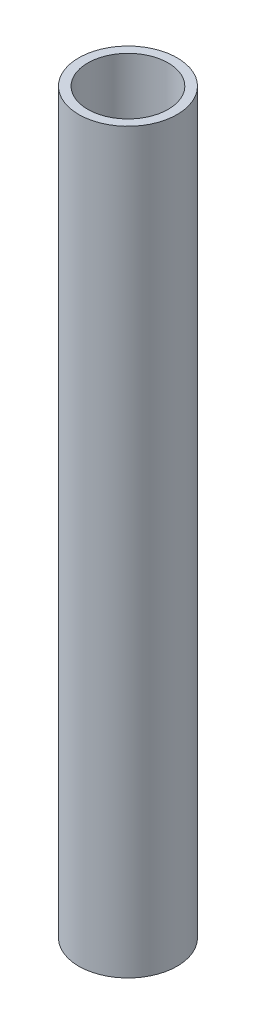
from build123d import *

# Parameters (mm, degrees)
ESBO_O1_R                = 11
ESBO_O1_R_2              = 9
RESSALTO_EXTRUS_O1_DEPTH = 165


with BuildPart() as part:
    # Esboço1 → Ressalto-extrusão1 (new body)
    with BuildSketch(Plane(origin=(0, 0, 0), x_dir=(1, 0, 0), z_dir=(0, 1, 0))):
        Circle(ESBO_O1_R)
        Circle(ESBO_O1_R_2, mode=Mode.SUBTRACT)
    extrude(amount=RESSALTO_EXTRUS_O1_DEPTH)


solid = part.part
